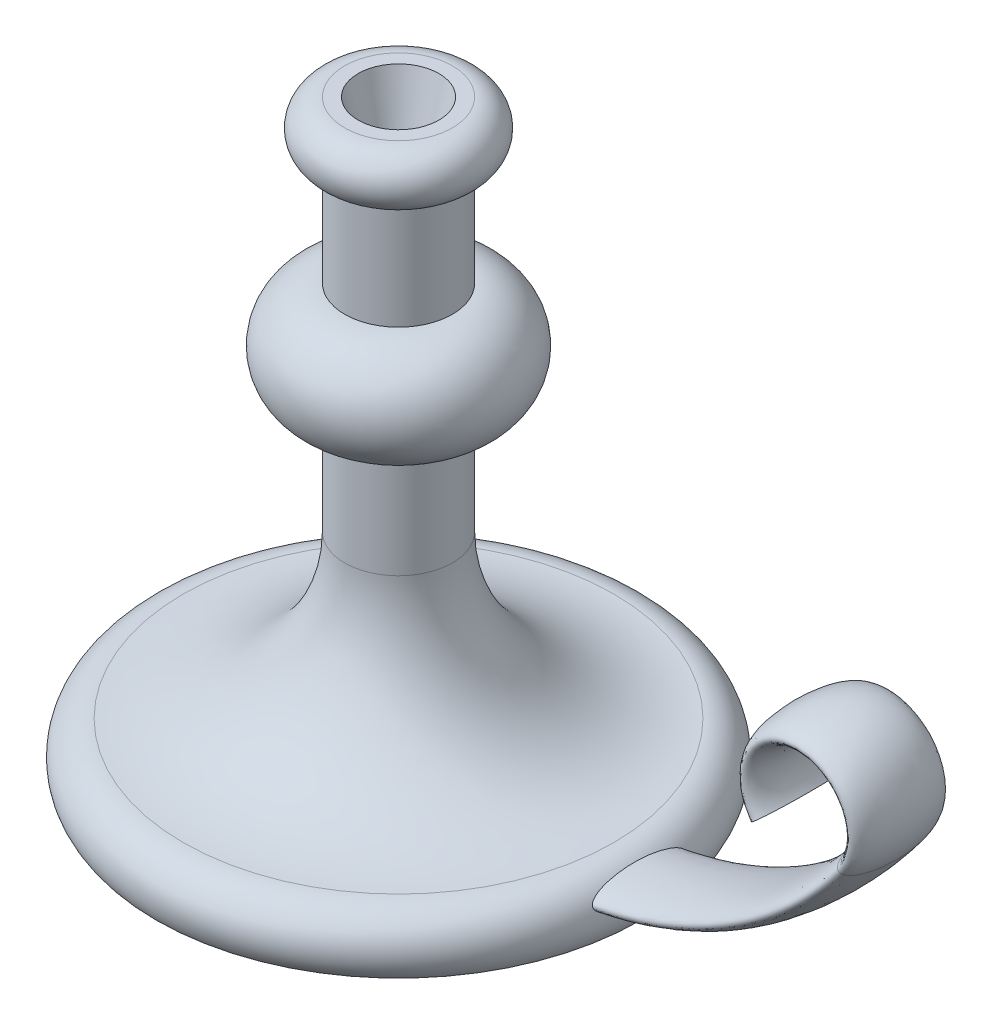
from build123d import *

# Parameters (mm, degrees)
SZKIC5_RX                  = 17.5
SZKIC5_RY                  = 5
SZKIC10_R                  = 15
WYTNIJ_WYCI_GNI_CIE1_DEPTH = 25
WYTNIJ_WYCI_GNI_CIE1_TAPER = 15


with BuildPart() as part:
    # Szkic1 → Obrót1 (revolve)
    with BuildSketch(Plane.XY):
        with BuildLine():
            Line((0, 0), (90, 0))
            ThreePointArc((90, 0), (91.180339887, 13.090169944), (80, 20))
            ThreePointArc((80, 20), (37.573593129, 37.573593129), (20, 80))
            Line((20, 80), (20, 120))
            ThreePointArc((20, 120), (40, 140), (20, 160))
            Line((20, 160), (20, 200))
            ThreePointArc((20, 200), (30, 210), (20, 220))
            Line((20, 220), (0, 220))
            Line((0, 220), (0, 0))
        make_face()
    revolve(axis=Axis((0, 220, 0), (0, -1, 0)))

    # Wyciągnięcie po ścieżce1: sweep along a path in Szkic4
    with BuildLine(Plane.XY) as wyci_gni_cie_po_cie_ce1_path:
        Line((0, 10), (61.049632822, 10))
        ThreePointArc((61.049632822, 10), (128.131672147, 25.83592135), (181.049632822, 70))
        ThreePointArc((181.049632822, 70), (165.049632822, 102), (149.049632822, 70))
    # Szkic5 → Wyciągnięcie po ścieżce1 (sweep)
    with BuildSketch(Plane(origin=(0, 0, 0), x_dir=(0, 0, -1), z_dir=(1, 0, 0))):
        with Locations((0, 10)):
            Ellipse(SZKIC5_RX, SZKIC5_RY)
    sweep(path=wyci_gni_cie_po_cie_ce1_path.line)

    # Szkic10 → Wytnij-wyciągnięcie1 (cut)
    with BuildSketch(Plane(origin=(0, 220, 0), x_dir=(1, 0, 0), z_dir=(0, 1, 0))):
        Circle(SZKIC10_R)
    extrude(amount=-WYTNIJ_WYCI_GNI_CIE1_DEPTH, taper=WYTNIJ_WYCI_GNI_CIE1_TAPER, mode=Mode.SUBTRACT)


solid = part.part
